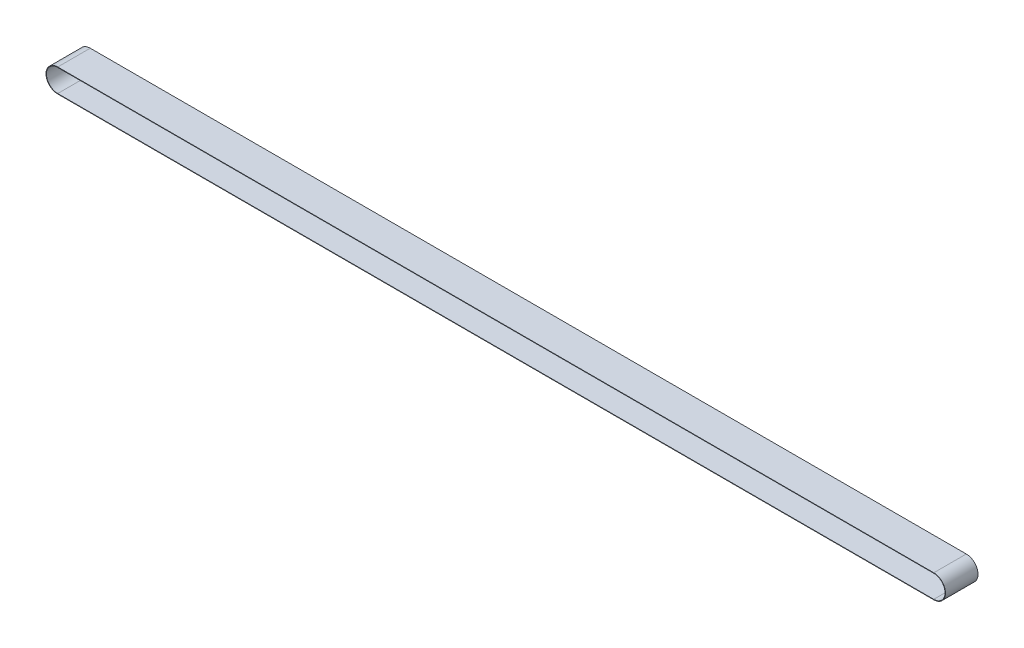
from build123d import *

# Parameters (mm, degrees)
EXTRUDE_1_DEPTH = 37.5


with BuildPart() as part:
    # 草图1 → 拉伸-薄壁1 (new body, symmetric)
    with BuildSketch(Plane.XY):
        with BuildLine():
            Line((1010, -27), (-1010, -27))
            ThreePointArc((-1010, -27), (-1037, 0), (-1010, 27))
            Line((-1010, 27), (1010, 27))
            ThreePointArc((1010, 27), (1037, 0), (1010, -27))
        make_face()
        with BuildLine():
            Line((1010, -26), (-1010, -26))
            ThreePointArc((-1010, -26), (-1036, 0), (-1010, 26))
            Line((-1010, 26), (1010, 26))
            ThreePointArc((1010, 26), (1036, 0), (1010, -26))
        make_face(mode=Mode.SUBTRACT)
    extrude(amount=EXTRUDE_1_DEPTH, both=True)


solid = part.part
